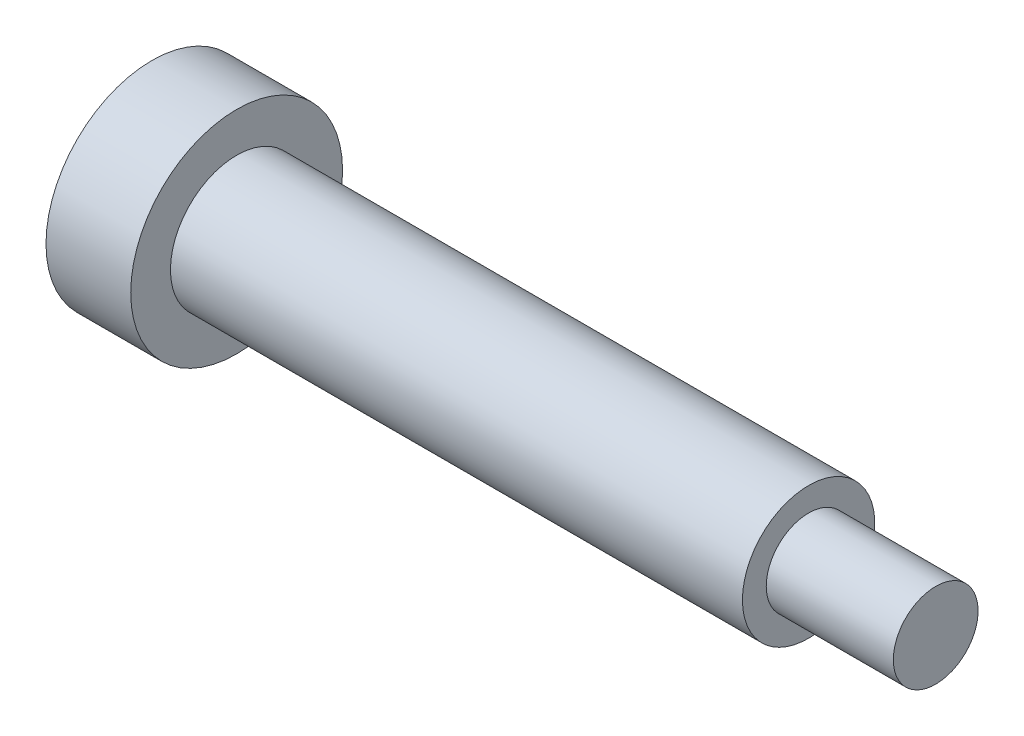
from build123d import *


with BuildPart() as part:
    # Sketch1 → Revolve1 (revolve)
    with BuildSketch(Plane.XY):
        Polygon((0, 0), (0, 5), (4, 5), (4, 3.125), (31, 3.125), (31, 2), (37, 2), (37, 0), align=None)
    revolve(axis=Axis((0, 0, 0), (1, 0, 0)))


solid = part.part
